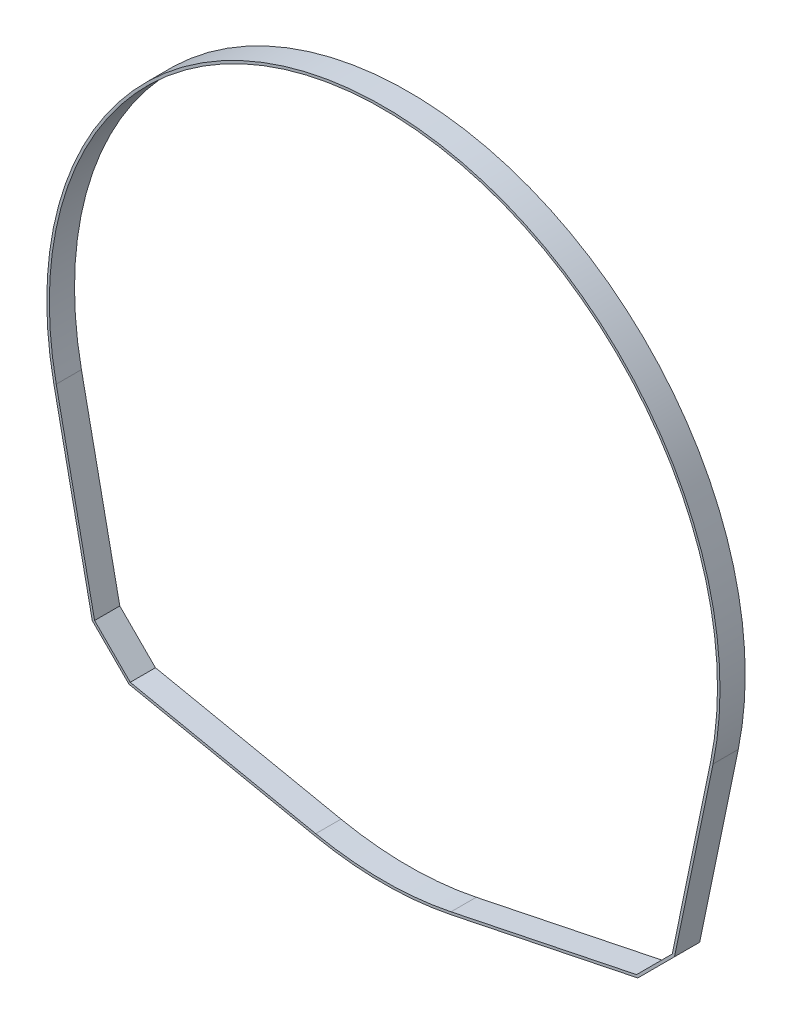
from build123d import *

# Parameters (mm, degrees)
BOSS_EXTRUDE1_DEPTH = 6.35


with BuildPart() as part:
    # Sketch1 → Boss-Extrude1 (new body)
    with BuildSketch(Plane.XY):
        with BuildLine():
            Line((-73.318041641, -64.069069833), (-83.016400713, -17.165487727))
            ThreePointArc((-83.016400713, -17.165487727), (0, 84.7725), (83.016400713, -17.165487727))
            Line((83.016400713, -17.165487727), (73.318041641, -64.069069833))
            Line((73.318041641, -64.069069833), (64.069069833, -73.318041641))
            Line((64.069069833, -73.318041641), (17.165487727, -83.016400713))
            ThreePointArc((17.165487727, -83.016400713), (0, -84.7725), (-17.165487727, -83.016400713))
            Line((-17.165487727, -83.016400713), (-64.069069833, -73.318041641))
            Line((-64.069069833, -73.318041641), (-73.318041641, -64.069069833))
        make_face()
        with BuildLine():
            Line((63.75441487, -72.734670991), (72.734670991, -63.75441487))
            Line((72.734670991, -63.75441487), (82.394555015, -17.036907295))
            ThreePointArc((82.394555015, -17.036907295), (0, 84.1375), (-82.394555015, -17.036907295))
            Line((-82.394555015, -17.036907295), (-72.734670991, -63.75441487))
            Line((-72.734670991, -63.75441487), (-63.75441487, -72.734670991))
            Line((-63.75441487, -72.734670991), (-17.036907295, -82.394555015))
            ThreePointArc((-17.036907295, -82.394555015), (0, -84.1375), (17.036907295, -82.394555015))
            Line((17.036907295, -82.394555015), (63.75441487, -72.734670991))
        make_face(mode=Mode.SUBTRACT)
    extrude(amount=BOSS_EXTRUDE1_DEPTH)


solid = part.part
